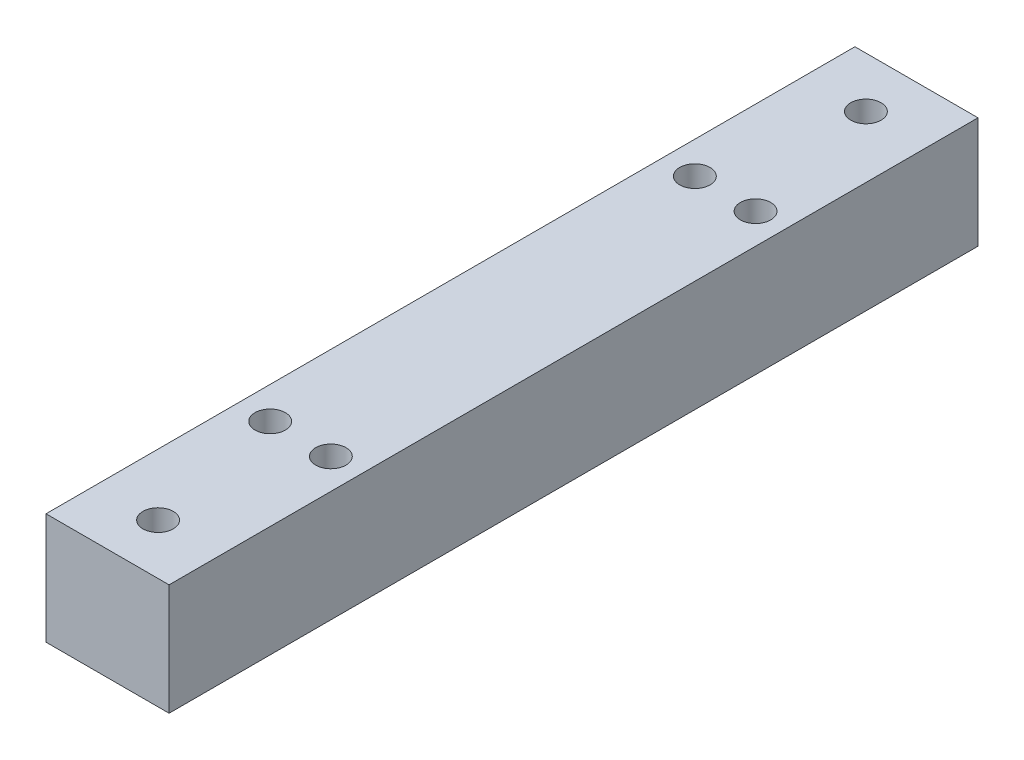
from build123d import *

# Parameters (mm, degrees)
SKETCH1_W           = 12.171
SKETCH1_H           = 11
BOSS_EXTRUDE1_DEPTH = 80
SKETCH2_R           = 1.5
CUT_EXTRUDE1_DEPTH  = 15
SKETCH4_R           = 1.5
CUT_EXTRUDE2_DEPTH  = 27


with BuildPart() as part:
    # Sketch1 → Boss-Extrude1 (new body)
    with BuildSketch(Plane.XY):
        with Locations((6.0855, 5.5)):
            Rectangle(SKETCH1_W, SKETCH1_H)
    extrude(amount=BOSS_EXTRUDE1_DEPTH)

    # Sketch2 → Cut-Extrude1 (cut)
    with BuildSketch(Plane(origin=(0, 11, 0), x_dir=(1, 0, 0), z_dir=(0, 1, 0))):
        with Locations((3.17, -61)):
            Circle(SKETCH2_R)
        with Locations((9.171, -61)):
            Circle(SKETCH2_R)
        with Locations((3.17, -19)):
            Circle(SKETCH2_R)
        with Locations((9.171, -19)):
            Circle(SKETCH2_R)
    extrude(amount=-CUT_EXTRUDE1_DEPTH, mode=Mode.SUBTRACT)

    # Sketch4 → Cut-Extrude2 (cut)
    with BuildSketch(Plane(origin=(0, 11, 0), x_dir=(1, 0, 0), z_dir=(0, 1, 0))):
        with Locations((6.085, -75)):
            Circle(SKETCH4_R)
        with Locations((6.085, -5)):
            Circle(SKETCH4_R)
    extrude(amount=-CUT_EXTRUDE2_DEPTH, mode=Mode.SUBTRACT)


solid = part.part
